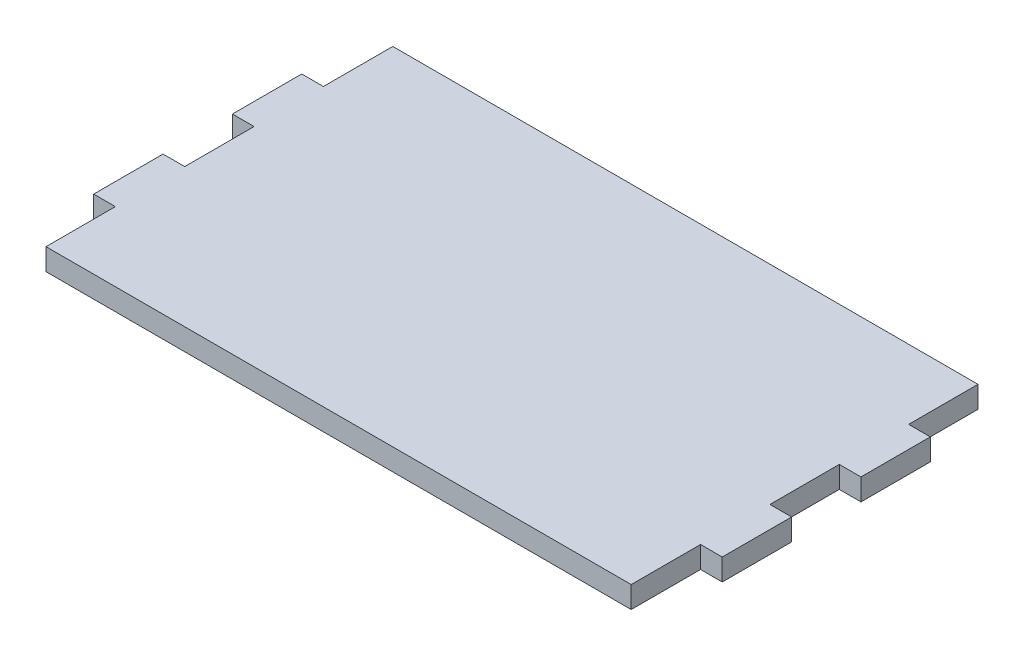
from build123d import *

# Parameters (mm, degrees)
BOSS_EXTRUDE1_DEPTH = 5


with BuildPart() as part:
    # Sketch1 → Boss-Extrude1 (new body)
    with BuildSketch(Plane(origin=(0, 0, 0), x_dir=(1, 0, 0), z_dir=(0, 1, 0))):
        Polygon((-67.5, 40), (-67.5, 24), (-72.5, 24), (-72.5, 8), (-67.5, 8), (-67.5, -8), (-72.5, -8), (-72.5, -24), (-67.5, -24), (-67.5, -40), (67.5, -40), (67.5, -24), (72.5, -24), (72.5, -8), (67.5, -8), (67.5, 8), (72.5, 8), (72.5, 24), (67.5, 24), (67.5, 40), align=None)
    extrude(amount=BOSS_EXTRUDE1_DEPTH)


solid = part.part
